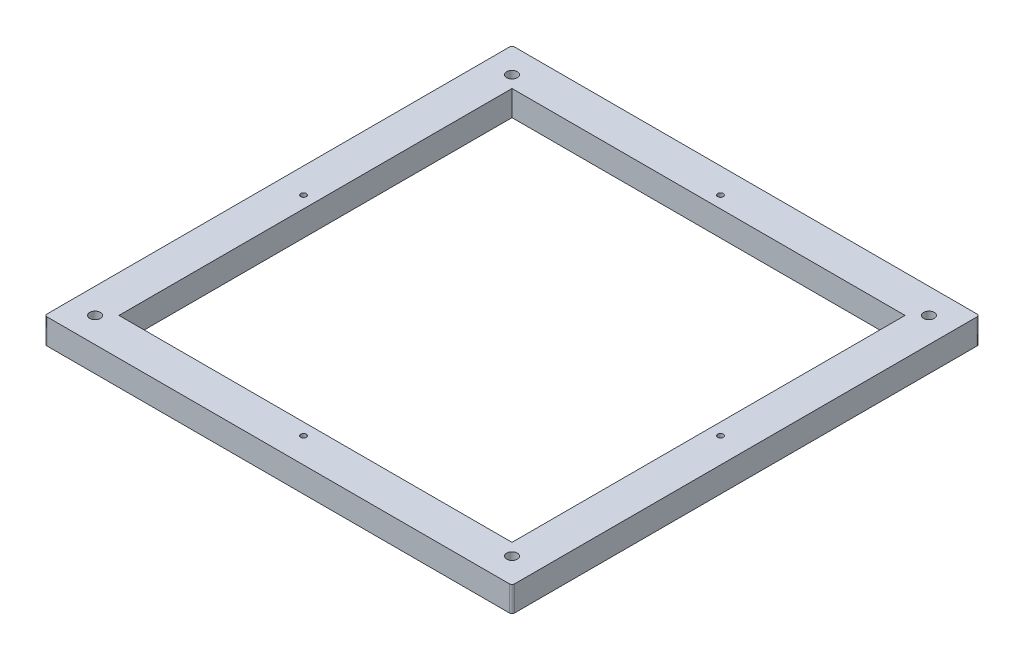
from build123d import *

# Parameters (mm, degrees)
ESQUISSE2_W             = 185
ESQUISSE2_H             = 185
ESQUISSE2_R             = 1.1
ESQUISSE2_W_2           = 155.54
ESQUISSE2_H_2           = 155.54
BOSS_EXTRU_1_DEPTH      = 10
CONG_1_R                = 1
ESQUISSE3_R             = 2.1
ENL_V_MAT_EXTRU_1_DEPTH = 8


with BuildPart() as part:
    # Esquisse2 → Boss.-Extru.1 (new body)
    with BuildSketch(Plane(origin=(0, 0, 0), x_dir=(1, 0, 0), z_dir=(0, 1, 0))):
        Rectangle(ESQUISSE2_W, ESQUISSE2_H)
        with Locations(Location((-82.5, 82.5, 0), (0, 0, 270))):  # turned: the seam where the file's is
            Circle(ESQUISSE2_R, mode=Mode.SUBTRACT)
        with Locations(Location((82.5, 82.5, 0), (0, 0, 270))):  # turned: the seam where the file's is
            Circle(ESQUISSE2_R, mode=Mode.SUBTRACT)
        with Locations(Location((0, 82.5, 0), (0, 0, 270))):  # turned: the seam where the file's is
            Circle(ESQUISSE2_R, mode=Mode.SUBTRACT)
        with Locations(Location((-82.5, 0, 0), (0, 0, 270))):  # turned: the seam where the file's is
            Circle(ESQUISSE2_R, mode=Mode.SUBTRACT)
        with Locations(Location((82.5, 0, 0), (0, 0, 270))):  # turned: the seam where the file's is
            Circle(ESQUISSE2_R, mode=Mode.SUBTRACT)
        with Locations(Location((82.5, -82.5, 0), (0, 0, 270))):  # turned: the seam where the file's is
            Circle(ESQUISSE2_R, mode=Mode.SUBTRACT)
        with Locations(Location((0, -82.5, 0), (0, 0, 270))):  # turned: the seam where the file's is
            Circle(ESQUISSE2_R, mode=Mode.SUBTRACT)
        with Locations(Location((-82.5, -82.5, 0), (0, 0, 270))):  # turned: the seam where the file's is
            Circle(ESQUISSE2_R, mode=Mode.SUBTRACT)
        Rectangle(ESQUISSE2_W_2, ESQUISSE2_H_2, mode=Mode.SUBTRACT)
    extrude(amount=-BOSS_EXTRU_1_DEPTH)

    # Congé1
    cong_1_edges = [part.edges().sort_by_distance(p)[0] for p in [
        (-92.5, -5, -92.5),
        (92.5, -5, -92.5),
        (92.5, -5, 92.5),
        (-92.5, -5, 92.5),
    ]]
    fillet(cong_1_edges, radius=CONG_1_R)

    # Esquisse3 → Enlèv. mat.-Extru.1 (cut)
    with BuildSketch(Plane(origin=(0, 0, 0), x_dir=(1, 0, 0), z_dir=(0, 1, 0))):
        with Locations(Location((-82.5, -82.5, 0), (0, 0, 270))):  # turned: the seam where the file's is
            Circle(ESQUISSE3_R)
        with Locations(Location((-82.5, 82.5, 0), (0, 0, 270))):  # turned: the seam where the file's is
            Circle(ESQUISSE3_R)
        with Locations(Location((82.5, 82.5, 0), (0, 0, 270))):  # turned: the seam where the file's is
            Circle(ESQUISSE3_R)
        with Locations(Location((82.5, -82.5, 0), (0, 0, 270))):  # turned: the seam where the file's is
            Circle(ESQUISSE3_R)
    extrude(amount=-ENL_V_MAT_EXTRU_1_DEPTH, mode=Mode.SUBTRACT)


solid = part.part
